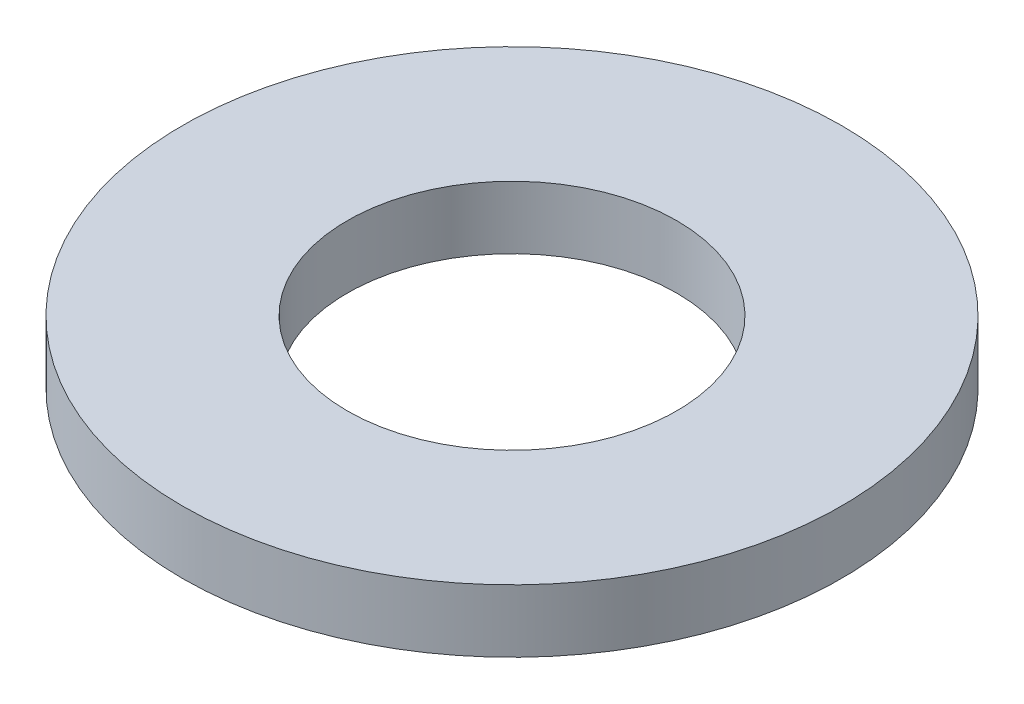
from build123d import *

# Parameters (mm, degrees)
SZKIC1_R                    = 10.5
SZKIC1_R_2                  = 5.25
DODANIE_WYCI_GNI_CIE1_DEPTH = 2


with BuildPart() as part:
    # Szkic1 → Dodanie-wyciągnięcie1 (new body)
    with BuildSketch(Plane(origin=(0, 0, 0), x_dir=(1, 0, 0), z_dir=(0, 1, 0))):
        Circle(SZKIC1_R)
        Circle(SZKIC1_R_2, mode=Mode.SUBTRACT)
    extrude(amount=DODANIE_WYCI_GNI_CIE1_DEPTH)


solid = part.part
